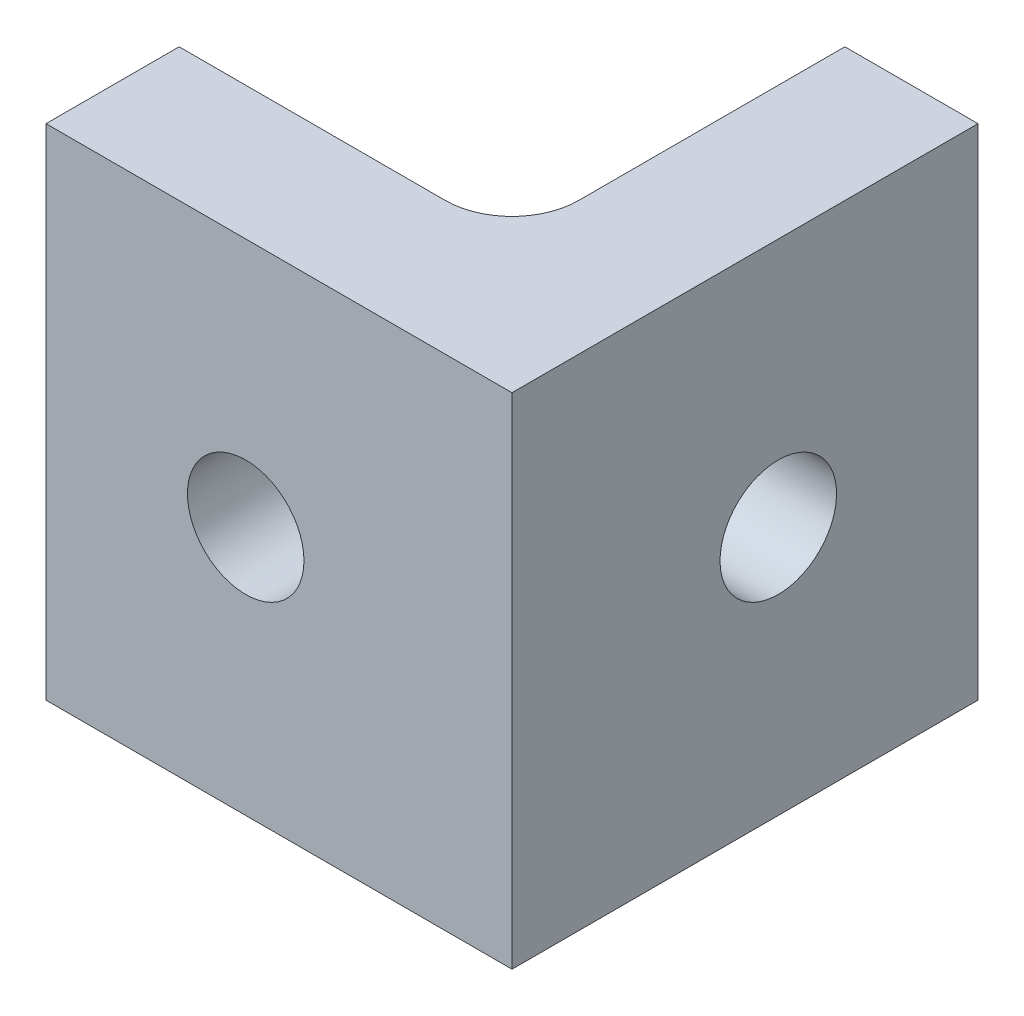
from build123d import *

# Parameters (mm, degrees)
SKETCH_1_W          = 12
SKETCH_1_H          = 15
SKETCH_1_R          = 1.75
EXTRUDE_1_DEPTH     = 4
SKETCH_2_W          = 16
SKETCH_2_H          = 15
SKETCH_2_R          = 1.75
EXTRUDE_2_DEPTH     = 4
FILLET_1_R          = 2
SKETCH_3_W          = 2
SKETCH_3_H          = 15
CUT_EXTRUDE_1_DEPTH = 4
SKETCH_4_W          = 2
SKETCH_4_H          = 15
CUT_EXTRUDE_2_DEPTH = 4


with BuildPart() as part:
    # 草图1 → 凸台-拉伸1 (new body)
    with BuildSketch(Plane.XY):
        Rectangle(SKETCH_1_W, SKETCH_1_H)
        with Locations((2, 0)):
            Circle(SKETCH_1_R, mode=Mode.SUBTRACT)
    extrude(amount=EXTRUDE_1_DEPTH)

    # 草图2 → 凸台-拉伸2 (add)
    with BuildSketch(Plane(origin=(6, 0, 0), x_dir=(0, 0, -1), z_dir=(1, 0, 0))):
        with Locations((4, 0)):
            Rectangle(SKETCH_2_W, SKETCH_2_H)
        with Locations((4, 0)):
            Circle(SKETCH_2_R, mode=Mode.SUBTRACT)
    extrude(amount=EXTRUDE_2_DEPTH)

    # 圆角1
    fillet_1_edges = [part.edges().sort_by_distance(p)[0] for p in [
        (6, 0, 0),
    ]]
    fillet(fillet_1_edges, radius=FILLET_1_R)

    # 草图3 → 切除-拉伸1 (cut)
    with BuildSketch(Plane.ZY.offset(-6)):
        with Locations((-11, 0)):
            Rectangle(SKETCH_3_W, SKETCH_3_H)
    extrude(amount=-CUT_EXTRUDE_1_DEPTH, mode=Mode.SUBTRACT)

    # 草图4 → 切除-拉伸2 (cut)
    with BuildSketch(Plane(origin=(0, 0, 0), x_dir=(-1, 0, 0), z_dir=(0, 0, -1))):
        with Locations((5, 0)):
            Rectangle(SKETCH_4_W, SKETCH_4_H)
    extrude(amount=-CUT_EXTRUDE_2_DEPTH, mode=Mode.SUBTRACT)


solid = part.part
